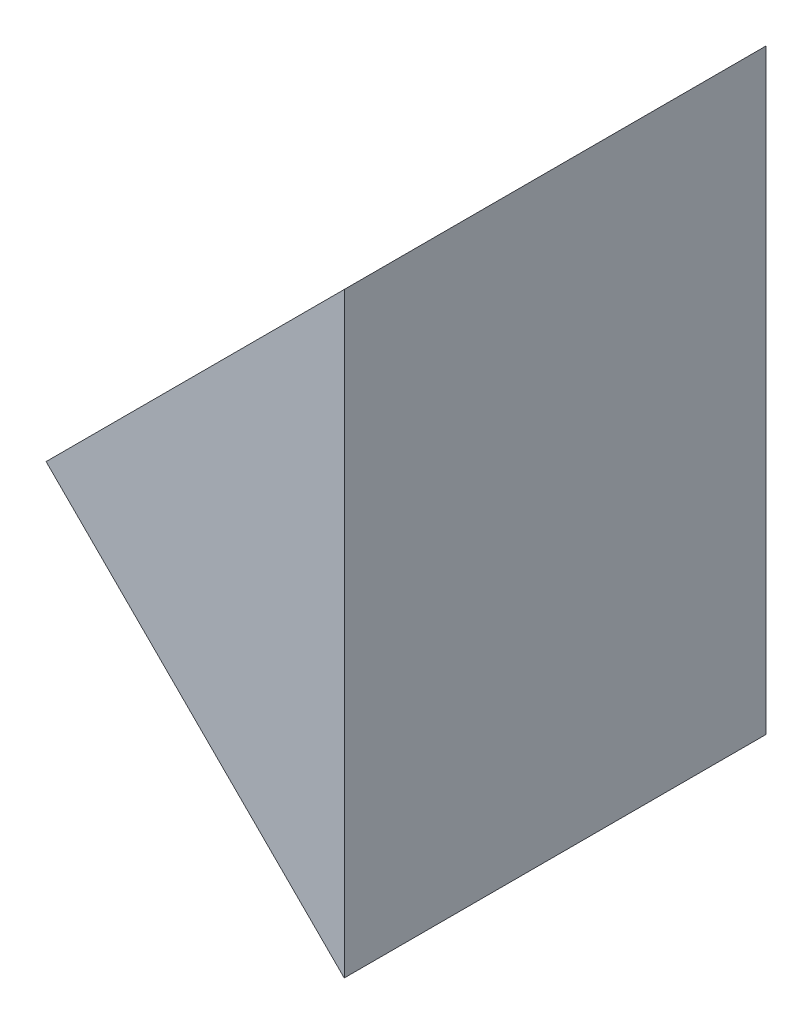
from build123d import *

# Parameters (mm, degrees)
EXTRUDE_1_DEPTH = 12.5


with BuildPart() as part:
    # 草图1 → 凸台-拉伸1 (new body)
    with BuildSketch(Plane.XY):
        Polygon((138.691674881, 34.439231382), (147.530509646, 43.278066147), (147.530509646, 25.600396617), align=None)
    extrude(amount=EXTRUDE_1_DEPTH)


solid = part.part
